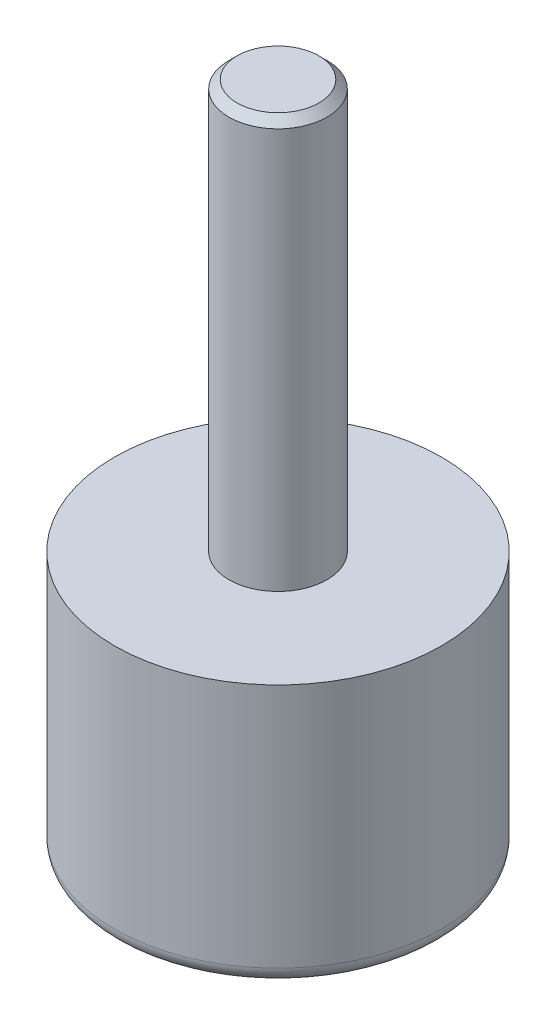
from build123d import *

# Parameters (mm, degrees)
CHANFREIN1_SIZE = 0.5
CONG_1_R        = 1


with BuildPart() as part:
    # Esquisse1 → Révolution1 (revolve)
    with BuildSketch(Plane.XY):
        with BuildLine():
            Line((-5.830951895, -18.5), (-10, -18.5))
            Line((-10, -18.5), (-10, -2.5))
            Line((-10, -2.5), (-3, -2.5))
            Line((-3, -2.5), (-3, 22.5))
            Line((-3, 22.5), (0, 22.5))
            Line((0, 22.5), (0, -22.5))
            ThreePointArc((0, -22.5), (-3.535533906, -21.403882032), (-5.830951895, -18.5))
        make_face()
    revolve(axis=Axis((0, 22.5, 0), (0, -1, 0)))

    # Chanfrein1
    chanfrein1_edges = [part.edges().sort_by_distance(p)[0] for p in [
        (3, 22.5, 0),
    ]]
    chamfer(chanfrein1_edges, length=CHANFREIN1_SIZE)

    # Congé1
    cong_1_edges = [part.edges().sort_by_distance(p)[0] for p in [
        (10, -18.5, 0),
    ]]
    fillet(cong_1_edges, radius=CONG_1_R)


solid = part.part
